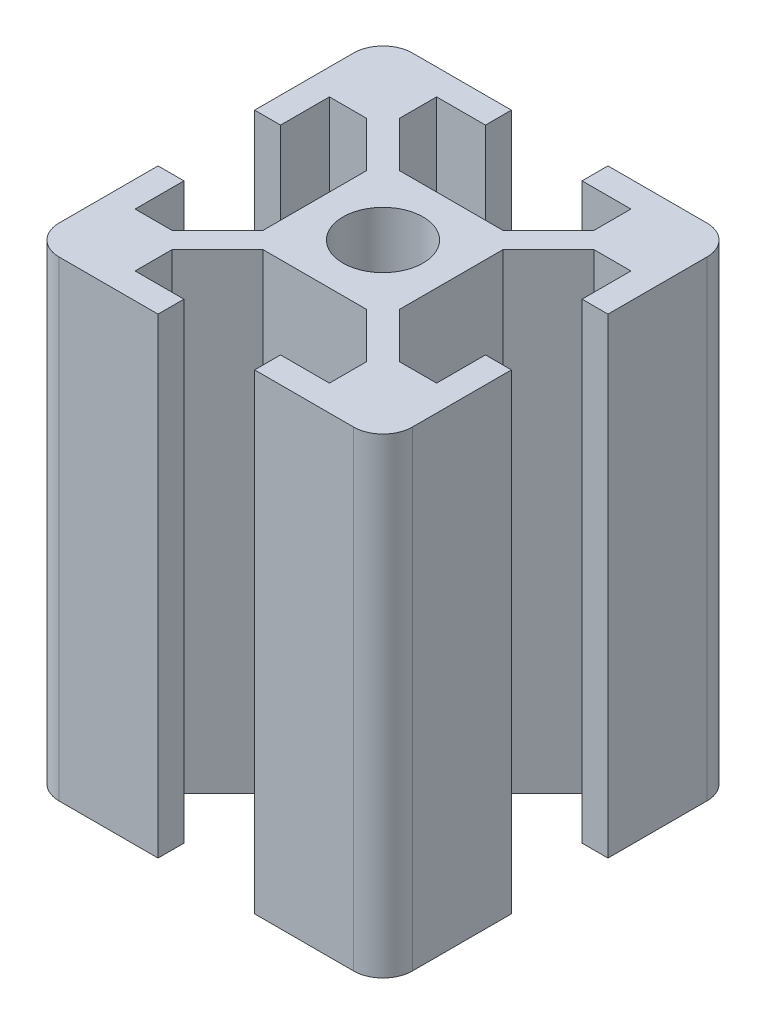
from build123d import *

# Parameters (mm, degrees)
SKETCH1_R           = 3.4
BOSS_EXTRUDE1_DEPTH = 40


with BuildPart() as part:
    # Sketch1 → Boss-Extrude1 (new body)
    with BuildSketch(Plane(origin=(0, 0, 0), x_dir=(1, 0, 0), z_dir=(0, 1, 0))):
        with BuildLine():
            Line((5.8, 4.385786438), (5.8, -4.385786438))
            Line((5.8, -4.385786438), (9.664213562, -8.25))
            Line((9.664213562, -8.25), (12.8, -8.25))
            Line((12.8, -8.25), (12.8, -4.1))
            Line((12.8, -4.1), (15, -4.1))
            Line((15, -4.1), (15, -12.5))
            ThreePointArc((15, -12.5), (14.267766953, -14.267766953), (12.5, -15))
            Line((12.5, -15), (4.1, -15))
            Line((4.1, -15), (4.1, -12.8))
            Line((4.1, -12.8), (8.25, -12.8))
            Line((8.25, -12.8), (8.25, -9.664213562))
            Line((8.25, -9.664213562), (4.385786438, -5.8))
            Line((4.385786438, -5.8), (-4.385786438, -5.8))
            Line((-4.385786438, -5.8), (-8.25, -9.664213562))
            Line((-8.25, -9.664213562), (-8.25, -12.8))
            Line((-8.25, -12.8), (-4.1, -12.8))
            Line((-4.1, -12.8), (-4.1, -15))
            Line((-4.1, -15), (-12.5, -15))
            ThreePointArc((-12.5, -15), (-14.267766953, -14.267766953), (-15, -12.5))
            Line((-15, -12.5), (-15, -4.1))
            Line((-15, -4.1), (-12.8, -4.1))
            Line((-12.8, -4.1), (-12.8, -8.25))
            Line((-12.8, -8.25), (-9.664213562, -8.25))
            Line((-9.664213562, -8.25), (-5.8, -4.385786438))
            Line((-5.8, -4.385786438), (-5.8, 4.385786438))
            Line((-5.8, 4.385786438), (-9.664213562, 8.25))
            Line((-9.664213562, 8.25), (-12.8, 8.25))
            Line((-12.8, 8.25), (-12.8, 4.1))
            Line((-12.8, 4.1), (-15, 4.1))
            Line((-15, 4.1), (-15, 12.5))
            ThreePointArc((-15, 12.5), (-14.267766953, 14.267766953), (-12.5, 15))
            Line((-12.5, 15), (-4.1, 15))
            Line((-4.1, 15), (-4.1, 12.8))
            Line((-4.1, 12.8), (-8.25, 12.8))
            Line((-8.25, 12.8), (-8.25, 9.664213562))
            Line((-8.25, 9.664213562), (-4.385786438, 5.8))
            Line((-4.385786438, 5.8), (4.385786438, 5.8))
            Line((4.385786438, 5.8), (8.25, 9.664213562))
            Line((8.25, 9.664213562), (8.25, 12.8))
            Line((8.25, 12.8), (4.1, 12.8))
            Line((4.1, 12.8), (4.1, 15))
            Line((4.1, 15), (12.5, 15))
            ThreePointArc((12.5, 15), (14.267766953, 14.267766953), (15, 12.5))
            Line((15, 12.5), (15, 4.1))
            Line((15, 4.1), (12.8, 4.1))
            Line((12.8, 4.1), (12.8, 8.25))
            Line((12.8, 8.25), (9.664213562, 8.25))
            Line((9.664213562, 8.25), (5.8, 4.385786438))
        make_face()
        Circle(SKETCH1_R, mode=Mode.SUBTRACT)
    extrude(amount=BOSS_EXTRUDE1_DEPTH)


solid = part.part
